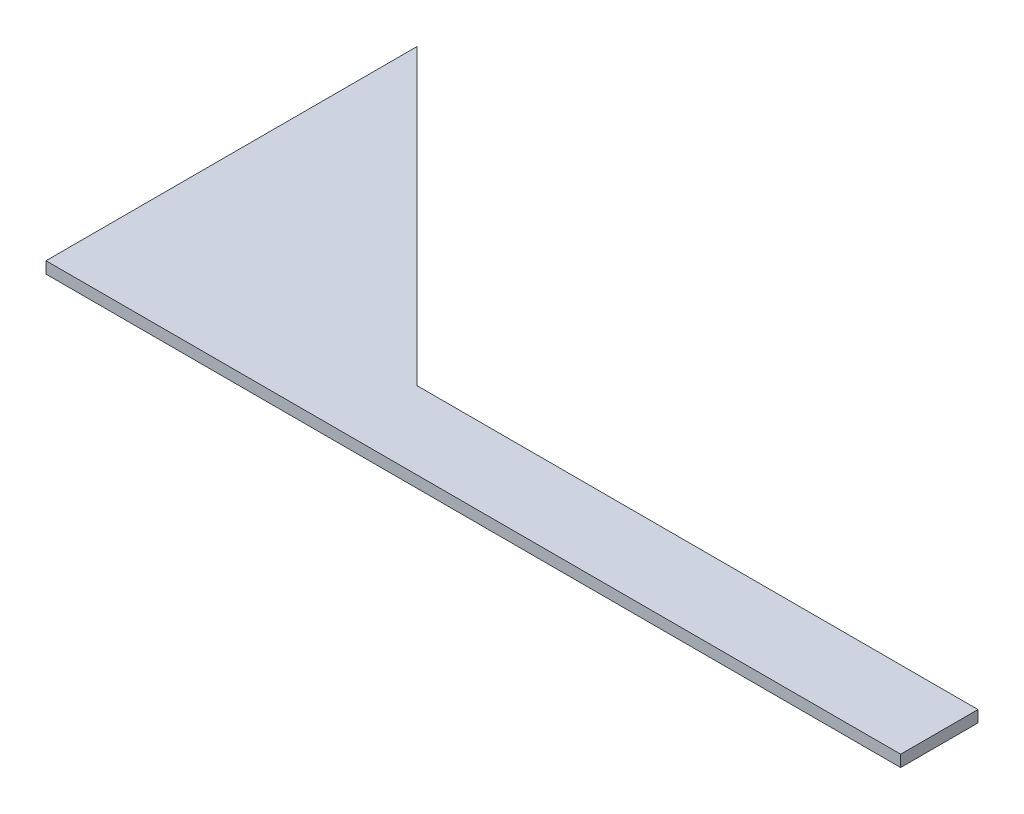
from build123d import *

# Parameters (mm, degrees)
BOSS_EXTRUDE1_DEPTH = 4.7625


with BuildPart() as part:
    # Sketch1 → Boss-Extrude1 (new body)
    with BuildSketch(Plane(origin=(0, 0, 0), x_dir=(1, 0, 0), z_dir=(0, 1, 0))):
        Polygon((152.4, 0), (0, 0), (0, 152.4), align=None)
        Polygon((120.65, 31.75), (152.4, 0), (350.901, 0), (350.901, 31.75), align=None)
    extrude(amount=BOSS_EXTRUDE1_DEPTH)


solid = part.part
